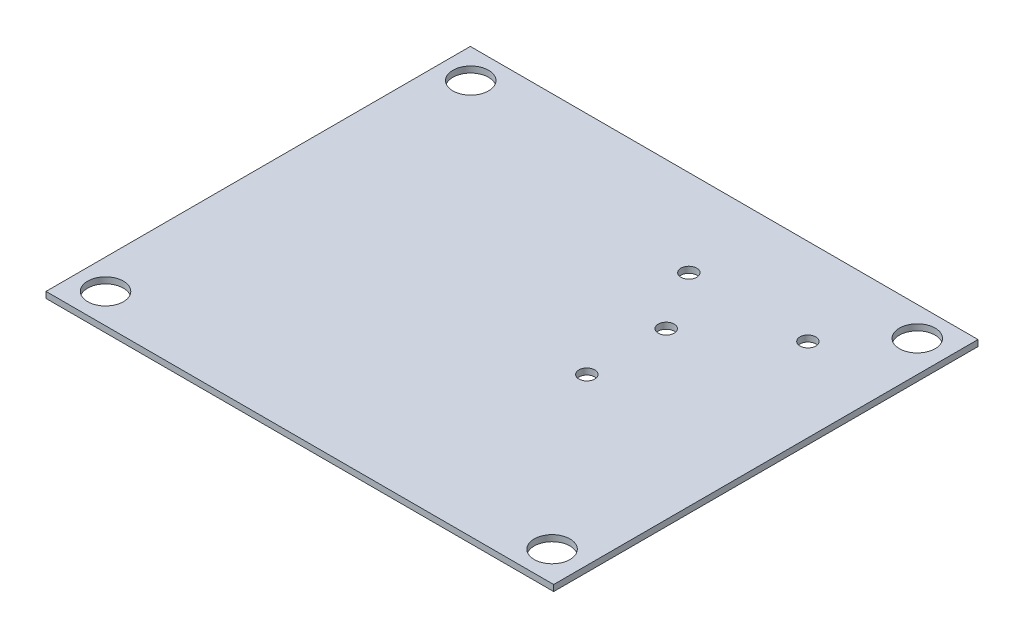
from build123d import *

# Parameters (mm, degrees)
SKETCH1_W           = 64.9732
SKETCH1_H           = 54.3052
SKETCH1_R           = 2.286
SKETCH1_R_2         = 1.016
BOSS_EXTRUDE1_DEPTH = 0.7874


with BuildPart() as part:
    # Sketch1 → Boss-Extrude1 (new body)
    with BuildSketch(Plane(origin=(0, 0, 0), x_dir=(1, 0, 0), z_dir=(0, 1, 0))):
        Rectangle(SKETCH1_W, SKETCH1_H)
        with Locations((-28.6766, -23.3426)):
            Circle(SKETCH1_R, mode=Mode.SUBTRACT)
        with Locations((28.4734, -23.3426)):
            Circle(SKETCH1_R, mode=Mode.SUBTRACT)
        with Locations((28.4734, 23.3934)):
            Circle(SKETCH1_R, mode=Mode.SUBTRACT)
        with Locations((-28.6766, 23.3934)):
            Circle(SKETCH1_R, mode=Mode.SUBTRACT)
        with Locations((11.3284, -1.7526)):
            Circle(SKETCH1_R_2, mode=Mode.SUBTRACT)
        with Locations((11.3284, 8.4074)):
            Circle(SKETCH1_R_2, mode=Mode.SUBTRACT)
        with Locations((6.5786, 16.0528)):
            Circle(SKETCH1_R_2, mode=Mode.SUBTRACT)
        with Locations((21.8186, 16.0528)):
            Circle(SKETCH1_R_2, mode=Mode.SUBTRACT)
    extrude(amount=BOSS_EXTRUDE1_DEPTH)


solid = part.part
